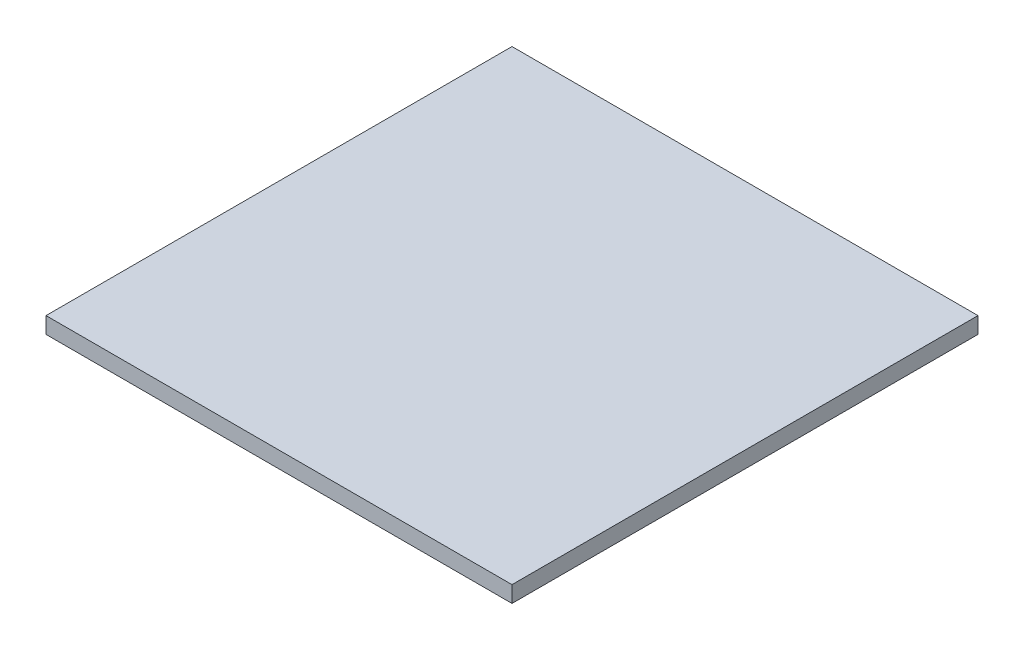
from build123d import *

# Parameters (mm, degrees)
SKETCH1_W           = 100
SKETCH1_H           = 100
BOSS_EXTRUDE1_DEPTH = 3.5


with BuildPart() as part:
    # Sketch1 → Boss-Extrude1 (new body)
    with BuildSketch(Plane(origin=(0, 0, 0), x_dir=(1, 0, 0), z_dir=(0, 1, 0))):
        with Locations((50, 50)):
            Rectangle(SKETCH1_W, SKETCH1_H)
    extrude(amount=BOSS_EXTRUDE1_DEPTH)


solid = part.part
